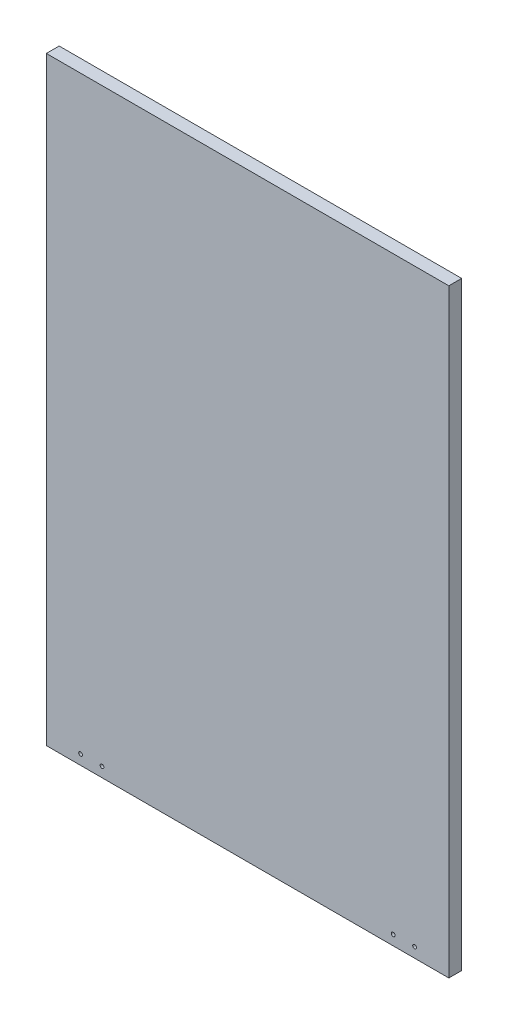
from build123d import *

# Parameters (mm, degrees)
SKETCH1_W           = 470
SKETCH1_H           = 700
SKETCH1_R           = 2.2
BOSS_EXTRUDE1_DEPTH = 15


with BuildPart() as part:
    # Sketch1 → Boss-Extrude1 (new body)
    with BuildSketch(Plane.XY):
        Rectangle(SKETCH1_W, SKETCH1_H)
        with Locations((-195, -338.4)):
            Circle(SKETCH1_R, mode=Mode.SUBTRACT)
        with Locations((195, -338.4)):
            Circle(SKETCH1_R, mode=Mode.SUBTRACT)
        with Locations((-170, -338.4)):
            Circle(SKETCH1_R, mode=Mode.SUBTRACT)
        with Locations((170, -338.4)):
            Circle(SKETCH1_R, mode=Mode.SUBTRACT)
    extrude(amount=BOSS_EXTRUDE1_DEPTH)


solid = part.part
